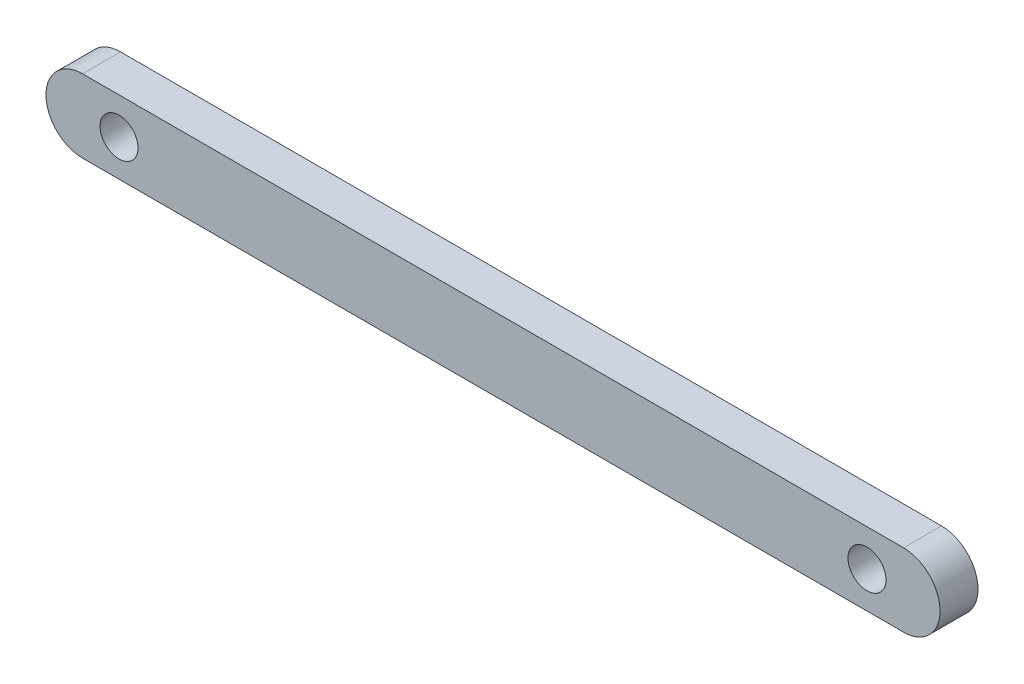
from build123d import *

# Parameters (mm, degrees)
BOSS_EXTRUDE1_DEPTH         = 3.302
F_1_4_0_13_DIAMETER_HOLE1_D = 3.302


with BuildPart() as part:
    # Sketch1 → Boss-Extrude1 (new body)
    with BuildSketch(Plane.XY):
        with BuildLine():
            Line((35.687, -3.175), (-35.687, -3.175))
            ThreePointArc((-35.687, -3.175), (-38.862, 0), (-35.687, 3.175))
            Line((-35.687, 3.175), (35.687, 3.175))
            ThreePointArc((35.687, 3.175), (38.862, 0), (35.687, -3.175))
        make_face()
    extrude(amount=-BOSS_EXTRUDE1_DEPTH)

    # 1_4 _0.13_ Diameter Hole1 (through all)
    with Locations(Plane.XY):
        with Locations((-32.512, 0), (32.512, 0)):
            Hole(F_1_4_0_13_DIAMETER_HOLE1_D / 2)


solid = part.part
